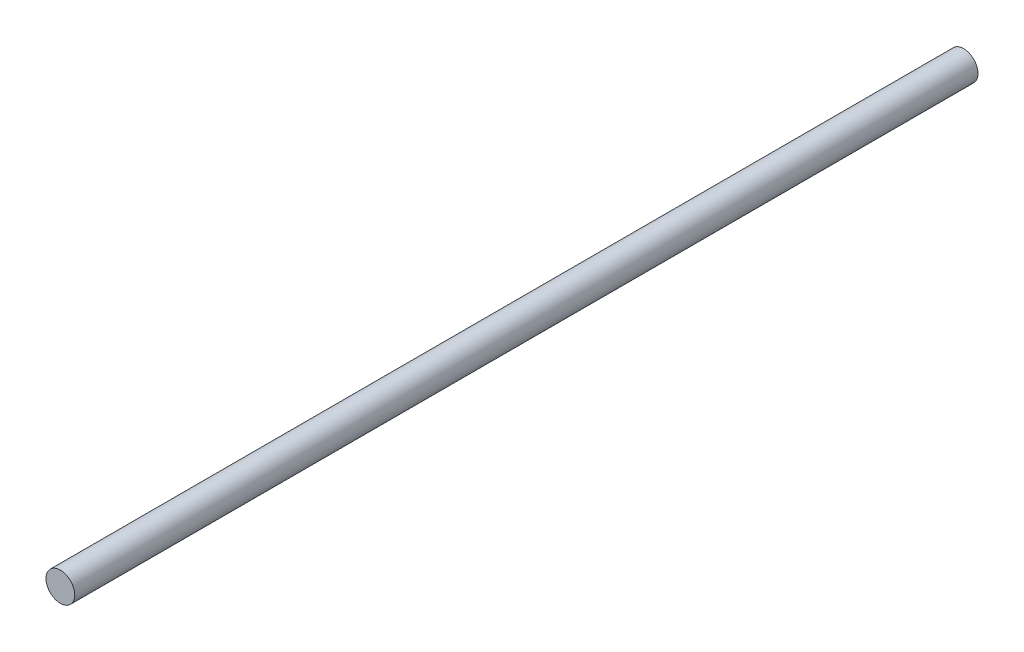
from build123d import *

# Parameters (mm, degrees)
SKETCH1_R           = 5.1
BOSS_EXTRUDE1_DEPTH = 320


with BuildPart() as part:
    # Sketch1 → Boss-Extrude1 (new body)
    with BuildSketch(Plane.XY):
        Circle(SKETCH1_R)
    extrude(amount=BOSS_EXTRUDE1_DEPTH)


solid = part.part
